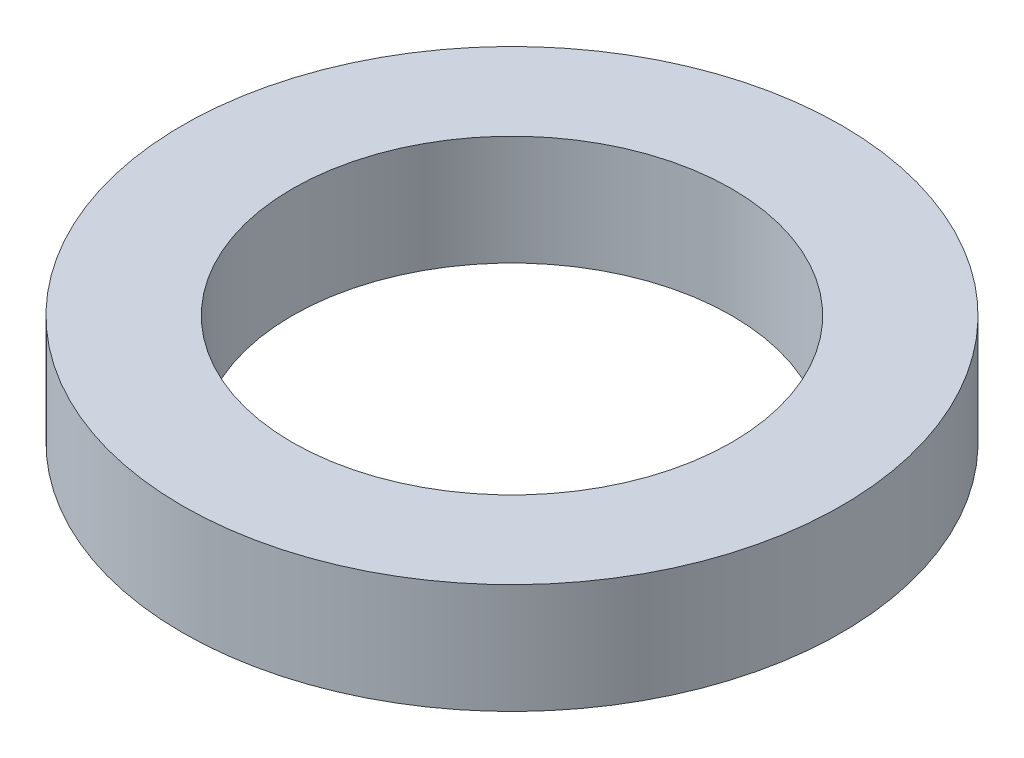
from build123d import *

# Parameters (mm, degrees)
SKETCH1_R           = 19.05
SKETCH1_R_2         = 12.7
BOSS_EXTRUDE1_DEPTH = 6.35


with BuildPart() as part:
    # Sketch1 → Boss-Extrude1 (new body)
    with BuildSketch(Plane(origin=(0, 0, 0), x_dir=(1, 0, 0), z_dir=(0, 1, 0))):
        Circle(SKETCH1_R)
        Circle(SKETCH1_R_2, mode=Mode.SUBTRACT)
    extrude(amount=BOSS_EXTRUDE1_DEPTH)


solid = part.part
